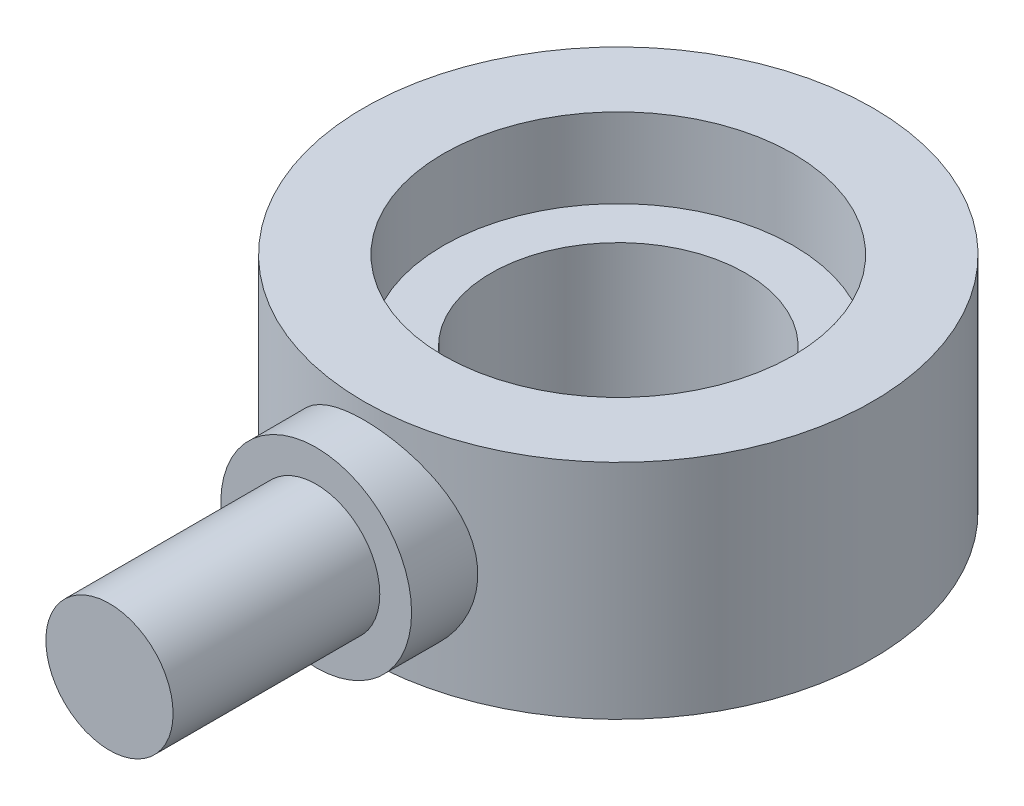
from build123d import *

# Parameters (mm, degrees)
SKETCH_1_R          = 8
SKETCH_1_R_2        = 4
EXTRUDE_1_DEPTH     = 7
SKETCH_2_R          = 3
EXTRUDE_2_DEPTH     = 9.5
SKETCH_5_R          = 4
CUT_EXTRUDE_1_DEPTH = 9.5
SKETCH_6_R          = 2
EXTRUDE_3_DEPTH     = 6.5
SKETCH_7_R          = 5.5
CUT_EXTRUDE_2_DEPTH = 2.5


with BuildPart() as part:
    # 草图1 → 凸台-拉伸1 (new body)
    with BuildSketch(Plane(origin=(0, 0, 0), x_dir=(1, 0, 0), z_dir=(0, 1, 0))):
        Circle(SKETCH_1_R)
        Circle(SKETCH_1_R_2, mode=Mode.SUBTRACT)
    extrude(amount=EXTRUDE_1_DEPTH)

    # 草图2 → 凸台-拉伸2 (add)
    with BuildSketch(Plane.XY):
        with Locations((0, 3.5)):
            Circle(SKETCH_2_R)
    extrude(amount=EXTRUDE_2_DEPTH)

    # 草图5 → 切除-拉伸1 (cut)
    with BuildSketch(Plane(origin=(0, 7, 0), x_dir=(1, 0, 0), z_dir=(0, 1, 0))):
        Circle(SKETCH_5_R)
    extrude(amount=-CUT_EXTRUDE_1_DEPTH, mode=Mode.SUBTRACT)

    # 草图6 → 凸台-拉伸3 (add)
    with BuildSketch(Plane.XY.offset(9.5)):
        with Locations((0, 3.5)):
            Circle(SKETCH_6_R)
    extrude(amount=EXTRUDE_3_DEPTH)

    # 草图7 → 切除-拉伸2 (cut)
    with BuildSketch(Plane(origin=(0, 7, 0), x_dir=(1, 0, 0), z_dir=(0, 1, 0))):
        Circle(SKETCH_7_R)
    extrude(amount=-CUT_EXTRUDE_2_DEPTH, mode=Mode.SUBTRACT)


solid = part.part
